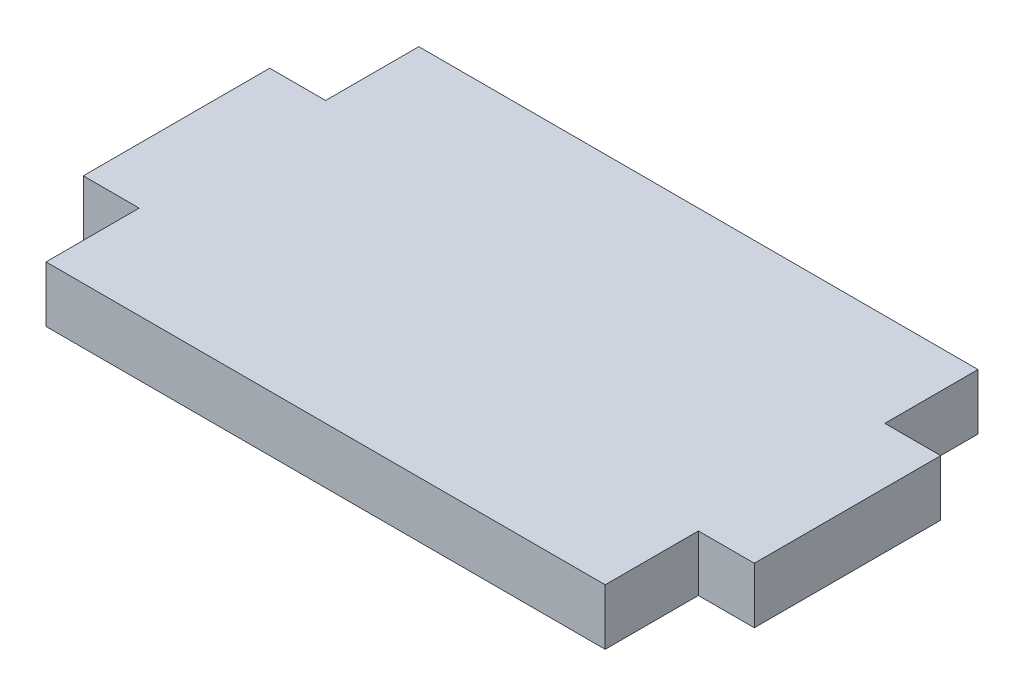
from build123d import *

# Parameters (mm, degrees)
BOSS_EXTRUDE1_DEPTH = 3


with BuildPart() as part:
    # Sketch1 → Boss-Extrude1 (new body)
    with BuildSketch(Plane(origin=(0, 0, 0), x_dir=(1, 0, 0), z_dir=(0, 1, 0))):
        Polygon((-15, 10), (-15, 5), (-18, 5), (-18, -5), (-15, -5), (-15, -10), (15, -10), (15, -5), (18, -5), (18, 5), (15, 5), (15, 10), align=None)
    extrude(amount=BOSS_EXTRUDE1_DEPTH)


solid = part.part
